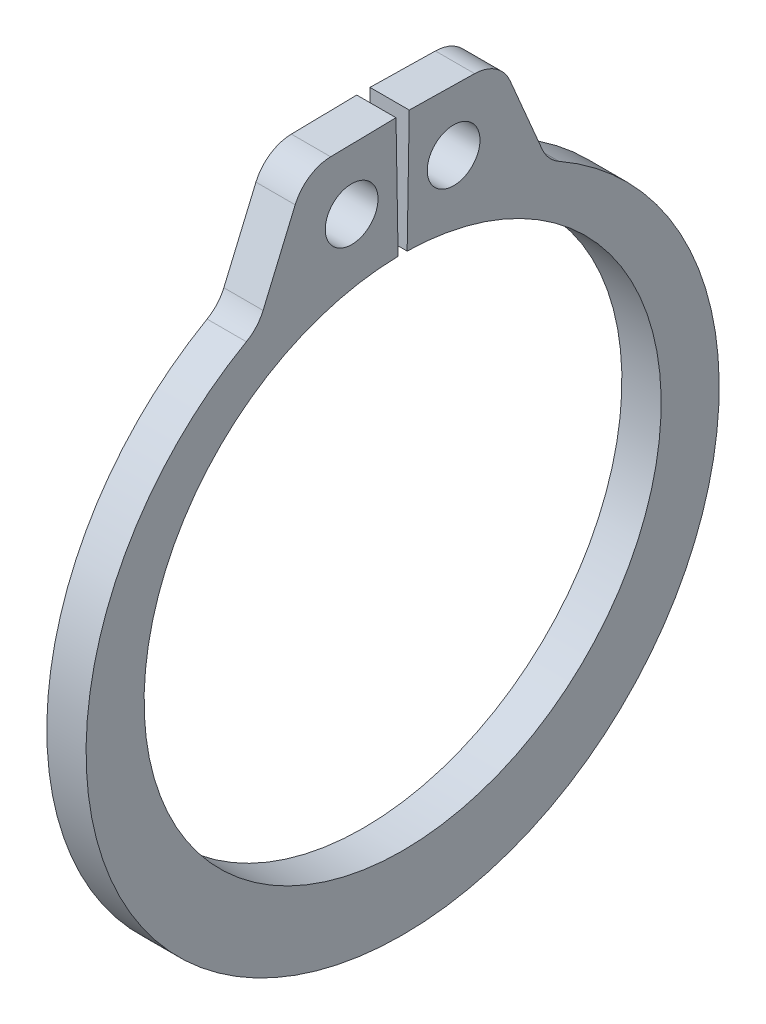
from build123d import *

# Parameters (mm, degrees)
SKETCH1_R      = 0.5969
EXTRUDE1_DEPTH = 0.4445
FILLET1_R      = 0.889


with BuildPart() as part:
    # Sketch1 → Extrude1 (new, symmetric)
    with BuildSketch(Plane(origin=(0, 0, 0), x_dir=(0, 0, -1), z_dir=(1, 0, 0))):
        with BuildLine():
            Line((-0.102178604, 5.853808301), (-0.150054045, 8.596590498))
            Line((-0.150054045, 8.596590498), (-2.207140693, 8.560683917))
            Line((-2.207140693, 8.560683917), (-3.281285866, 6.036528932))
            ThreePointArc((-3.281285866, 6.036528932), (0, -7.5057), (3.281285866, 6.036528932))
            Line((3.281285866, 6.036528932), (2.207140693, 8.560683917))
            Line((2.207140693, 8.560683917), (0.150054045, 8.596590498))
            Line((0.150054045, 8.596590498), (0.102178604, 5.853808301))
            ThreePointArc((0.102178604, 5.853808301), (0, -5.8547), (-0.102178604, 5.853808301))
        make_face()
        with Locations((-1.154659649, 7.207246109)):
            Circle(SKETCH1_R, mode=Mode.SUBTRACT)
        with Locations((1.154659649, 7.207246109)):
            Circle(SKETCH1_R, mode=Mode.SUBTRACT)
    extrude(amount=EXTRUDE1_DEPTH, both=True)

    # Fillet1
    fillet1_edges = [part.edges().sort_by_distance(p)[0] for p in [
        (0, 8.560683917, -2.207140693),
        (0, 6.036528932, -3.281285866),
        (0, 6.036528932, 3.281285866),
        (0, 8.560683917, 2.207140693),
    ]]
    fillet(fillet1_edges, radius=FILLET1_R)


solid = part.part
